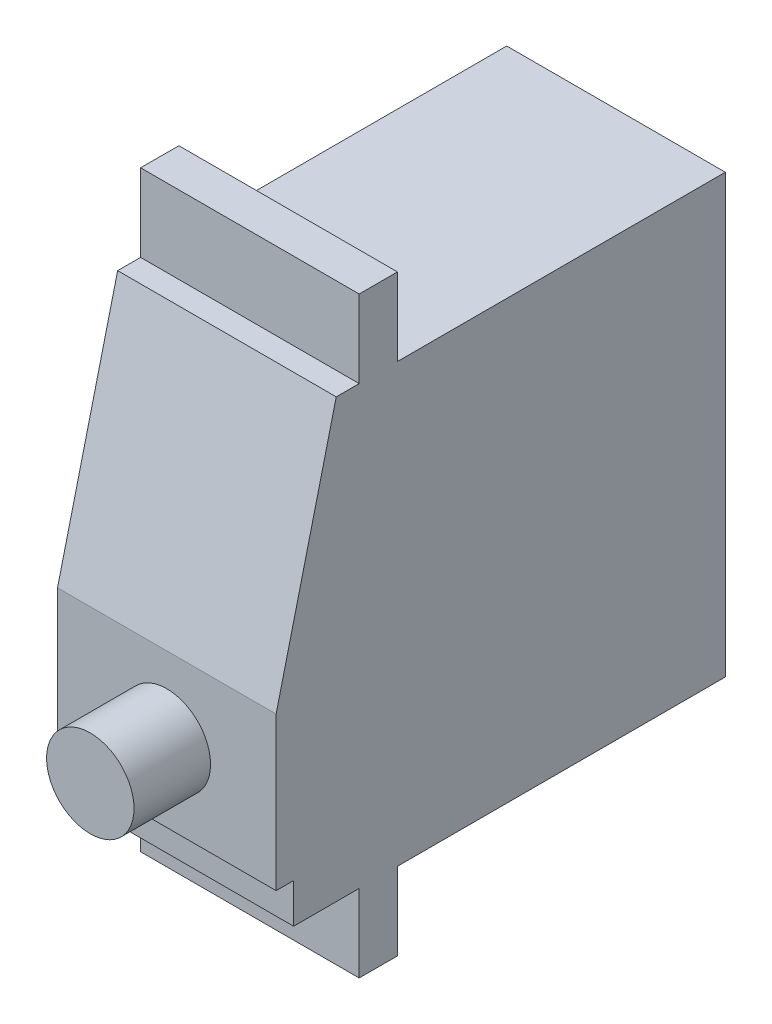
from build123d import *

# Parameters (mm, degrees)
BOSS_EXTRUDE1_DEPTH = 19.999999553
SKETCH2_W           = 29.999999329
SKETCH2_H           = 7.099999115
CUT_EXTRUDE1_DEPTH  = 55.335457568
SKETCH3_W           = 7.599998266
SKETCH3_H           = 7.099999115
CUT_EXTRUDE2_DEPTH  = 55.335457568
SKETCH4_W           = 1.599997282
SKETCH4_H           = 3.620889969
CUT_EXTRUDE3_DEPTH  = 55.335457568
BOSS_EXTRUDE2_REACH = 56.335
SKETCH6_W           = 3.500001505
SKETCH6_H           = 7.10000284
SKETCH7_R           = 4
BOSS_EXTRUDE3_DEPTH = 7
MOVE_FACE2_BY       = 6
MOVE_FACE3_BY       = 6


with BuildPart() as part:
    # Sketch1 → Boss-Extrude1 (new body)
    with BuildSketch(Plane(origin=(10, 0, 0), x_dir=(0, 0, -1), z_dir=(1, 0, 0))):
        Polygon((0, 29.379108921), (-35.59999913, 29.379108921), (-41.0999991, 7.000000216), (-41.0999991, -17.7208893), (0, -17.7208893), align=None)
    extrude(amount=-BOSS_EXTRUDE1_DEPTH)

    # Sketch2 → Cut-Extrude1 (cut, through all)
    with BuildSketch(Plane(origin=(10, 0, 0), x_dir=(0, 0, -1), z_dir=(1, 0, 0))):
        with Locations((-14.999999665, -14.170889742)):
            Rectangle(SKETCH2_W, SKETCH2_H)
    extrude(amount=-CUT_EXTRUDE1_DEPTH, mode=Mode.SUBTRACT)

    # Sketch3 → Cut-Extrude2 (cut, through all)
    with BuildSketch(Plane(origin=(10, 0, 0), x_dir=(0, 0, -1), z_dir=(1, 0, 0))):
        with Locations((-37.299999967, -14.170889742)):
            Rectangle(SKETCH3_W, SKETCH3_H)
    extrude(amount=-CUT_EXTRUDE2_DEPTH, mode=Mode.SUBTRACT)

    # Sketch4 → Cut-Extrude3 (cut, through all)
    with BuildSketch(Plane(origin=(10, 0, 0), x_dir=(0, 0, -1), z_dir=(1, 0, 0))):
        with Locations((-40.300000459, -8.810445201)):
            Rectangle(SKETCH4_W, SKETCH4_H)
    extrude(amount=-CUT_EXTRUDE3_DEPTH, mode=Mode.SUBTRACT)

    # Boss-Extrude2: up to this plane
    boss_extrude2_end = Plane(origin=(-9.873244788, 0, -0.038787862), z_dir=(-0.9999922832070416, 0, -0.003928552706520363))
    # Sketch6 → Boss-Extrude2 (add, up to the surface)
    with BuildSketch(Plane(origin=(10, 0, 0), x_dir=(0, 0, -1), z_dir=(1, 0, 0)), mode=Mode.PRIVATE) as boss_extrude2_sk1:
        with Locations((-31.750000082, 32.929110341)):
            Rectangle(SKETCH6_W, SKETCH6_H)
    boss_extrude2_tool1 = split(extrude(boss_extrude2_sk1.sketch, amount=-BOSS_EXTRUDE2_REACH, mode=Mode.PRIVATE), bisect_by=boss_extrude2_end, keep=Keep.BOTH, mode=Mode.PRIVATE)
    add(boss_extrude2_tool1.solids().sort_by_distance((10, 32.92911, 31.75))[0])

    # Sketch7 → Boss-Extrude3 (add)
    with BuildSketch(Plane.XY.offset(41.0999991)):
        Circle(SKETCH7_R)
    extrude(amount=BOSS_EXTRUDE3_DEPTH)

    # Move Face2: a face moved outward by 6.0
    extrude(part.faces().sort_by_distance((0, 0, 48.0999991))[0], amount=MOVE_FACE2_BY, dir=(0, 0, 1))

    # Move Face3: a face moved inward by 6.0
    extrude(part.faces().sort_by_distance((0, 0, 54.0999991))[0], amount=MOVE_FACE3_BY, dir=(0, 0, -1), mode=Mode.SUBTRACT)


solid = part.part
